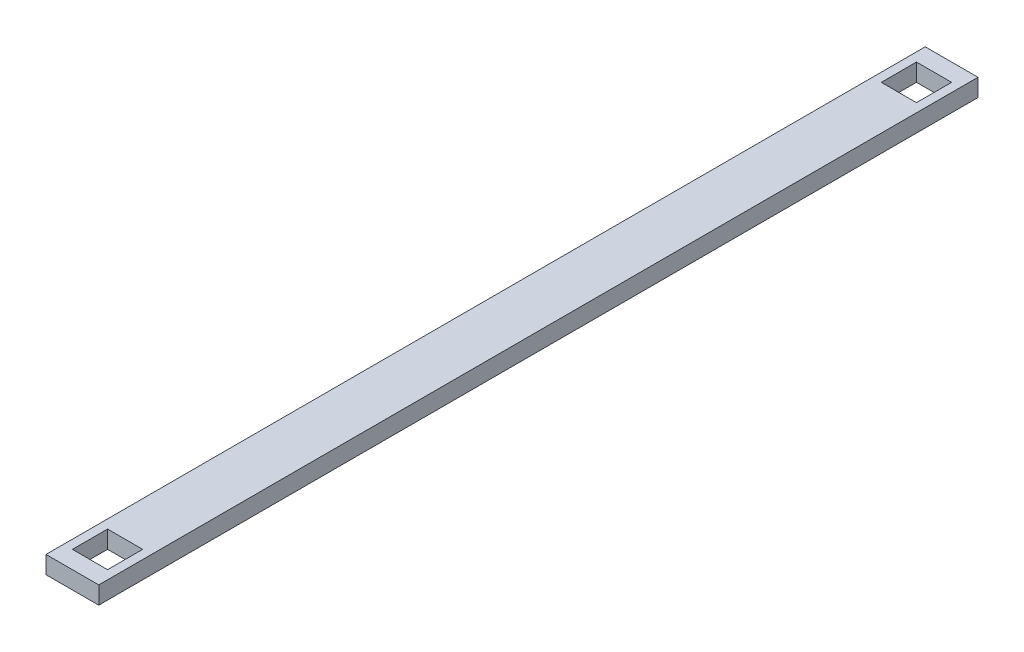
from build123d import *

# Parameters (mm, degrees)
ESBO_O1_W                = 3
ESBO_O1_H                = 1
RESSALTO_EXTRUS_O1_DEPTH = 50
ESBO_O3_W                = 2
ESBO_O3_H                = 2
CORTE_EXTRUS_O1_DEPTH    = 44


with BuildPart() as part:
    # Esboço1 → Ressalto-extrusão1 (new body)
    with BuildSketch(Plane.XY):
        with Locations((1.5, 0.5)):
            Rectangle(ESBO_O1_W, ESBO_O1_H)
    extrude(amount=-RESSALTO_EXTRUS_O1_DEPTH)

    # Esboço3 → Corte-extrusão1 (cut)
    with BuildSketch(Plane(origin=(0, 1, 0), x_dir=(1, 0, 0), z_dir=(0, 1, 0))):
        with Locations((1.5, 2)):
            Rectangle(ESBO_O3_W, ESBO_O3_H)
        with Locations((1.5, 48)):
            Rectangle(ESBO_O3_W, ESBO_O3_H)
    extrude(amount=-CORTE_EXTRUS_O1_DEPTH, mode=Mode.SUBTRACT)


solid = part.part
